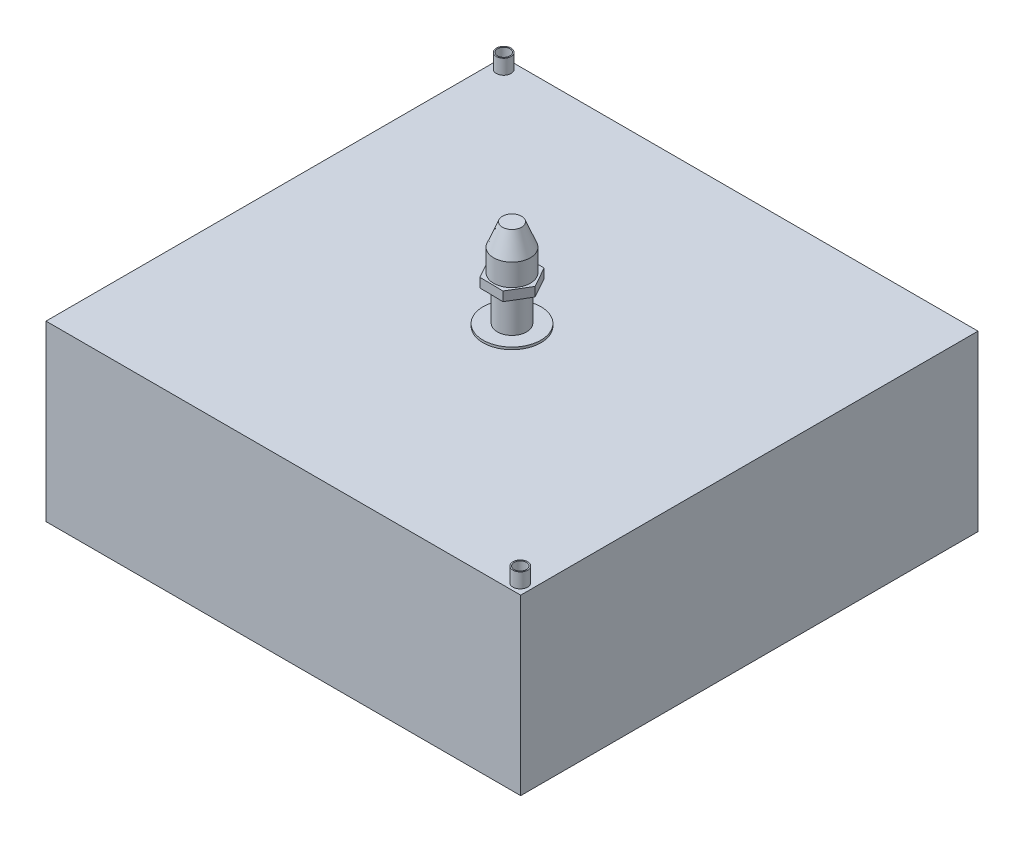
from build123d import *

# Parameters (mm, degrees)
SKETCH1_W      = 410
SKETCH1_H      = 150
EXTRUDE1_DEPTH = 197.5
SKETCH2_R      = 6.35
EXTRUDE2_DEPTH = 12.7
SHELL1_T       = -1
SKETCH3_R      = 25
EXTRUDE3_DEPTH = 2
SKETCH4_R      = 12.7
EXTRUDE4_DEPTH = 30
EXTRUDE5_DEPTH = 8


with BuildPart() as part:
    # Sketch1 → Extrude1 (new, symmetric)
    with BuildSketch(Plane.XY):
        with Locations((0, 75)):
            Rectangle(SKETCH1_W, SKETCH1_H)
    extrude(amount=EXTRUDE1_DEPTH, both=True)

    # Sketch2 → Extrude2 (add)
    with BuildSketch(Plane(origin=(0, 150, 0), x_dir=(1, 0, 0), z_dir=(0, 1, 0))):
        with Locations(Location((-195.680339288, 188.521302485, 0), (0, 0, 90))):
            Circle(SKETCH2_R)
        with Locations(Location((195.680339288, -188.521302485, 0), (0, 0, 90))):
            Circle(SKETCH2_R)
    extrude(amount=EXTRUDE2_DEPTH)

    # Shell1
    shell1_openings = [part.faces().sort_by_distance(p)[0] for p in [
        (-195.680339288, 162.7, -188.521302485),
        (195.680339288, 162.7, 188.521302485),
    ]]
    offset(amount=SHELL1_T, openings=shell1_openings, kind=Kind.INTERSECTION)

    # Sketch3 → Extrude3 (add)
    with BuildSketch(Plane(origin=(0, 150, 0), x_dir=(1, 0, 0), z_dir=(0, 1, 0))):
        with Locations(Location((0, 0, 0), (0, 0, 90))):
            Circle(SKETCH3_R)
    extrude(amount=EXTRUDE3_DEPTH)

    # Sketch4 → Extrude4 (add)
    with BuildSketch(Plane(origin=(0, 152, 0), x_dir=(1, 0, 0), z_dir=(0, 1, 0))):
        with Locations(Location((0, 0, 0), (0, 0, 270))):
            Circle(SKETCH4_R)
    extrude(amount=EXTRUDE4_DEPTH)

    # Sketch5 → Extrude5 (add)
    with BuildSketch(Plane(origin=(0, 182, 0), x_dir=(1, 0, 0), z_dir=(0, 1, 0))):
        Polygon((10.396549201, 17.327582002), (-9.807851599, 17.667466721), (-20.204400801, 0.339884719), (-10.396549201, -17.327582002), (9.807851599, -17.667466721), (20.204400801, -0.339884719), align=None)
    extrude(amount=EXTRUDE5_DEPTH)

    # Sketch6 → Revolve1 (revolve)
    with BuildSketch(Plane.XY, mode=Mode.PRIVATE) as revolve1_sk:
        Polygon((0, 190), (15.875, 190), (15.875, 209.05), (8.255, 228.1), (0, 228.1), align=None)
    revolve(revolve1_sk.sketch.rotate(Axis((0, 0, 0), (0, 1, 0)), 90), axis=Axis((0, 0, 0), (0, 1, 0)))


solid = part.part
